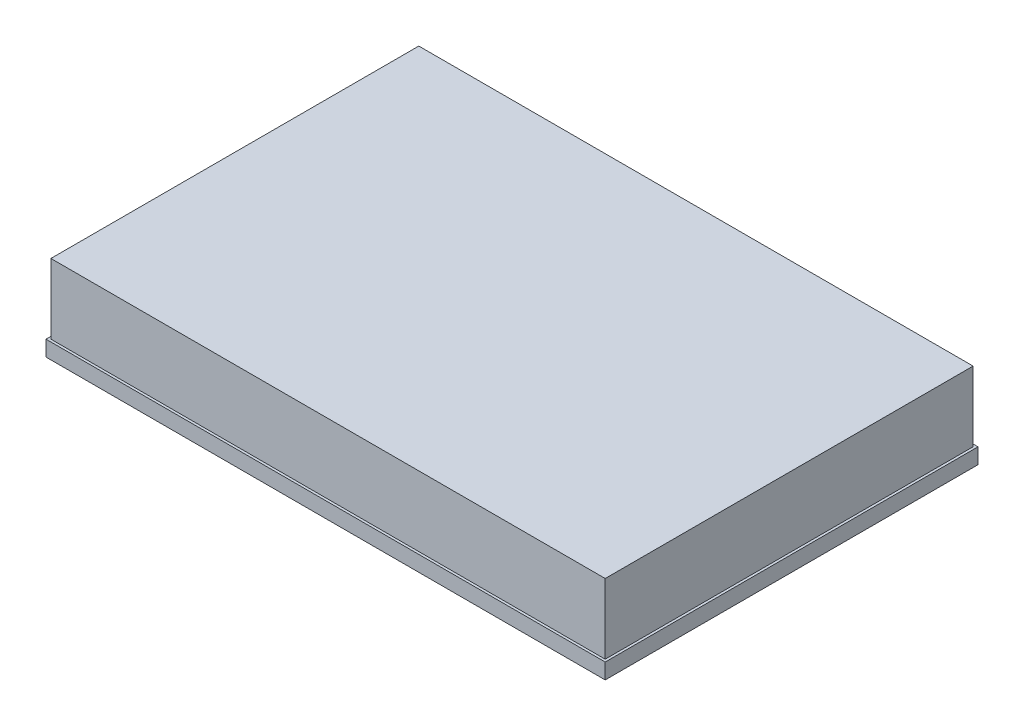
from build123d import *

# Parameters (mm, degrees)
SKETCH1_W           = 114.3
SKETCH1_H           = 76.2
BOSS_EXTRUDE1_DEPTH = 3.175
BOSS_EXTRUDE4_DEPTH = 14.2875


with BuildPart() as part:
    # Sketch1 → Boss-Extrude1 (new body)
    with BuildSketch(Plane(origin=(0, 0, 0), x_dir=(1, 0, 0), z_dir=(0, 1, 0))):
        with Locations((-57.15, 38.1)):
            Rectangle(SKETCH1_W, SKETCH1_H)
    extrude(amount=BOSS_EXTRUDE1_DEPTH)

    # Sketch3 → Boss-Extrude4 (add)
    with BuildSketch(Plane(origin=(0, 3.175, 0), x_dir=(1, 0, 0), z_dir=(0, 1, 0))):
        Polygon((-0.5, 75.7), (-113.8, 75.7), (-113.8, 0.5), (-0.5, 0.5), (-0.5, 14.034671148), align=None)
    extrude(amount=BOSS_EXTRUDE4_DEPTH)


solid = part.part
